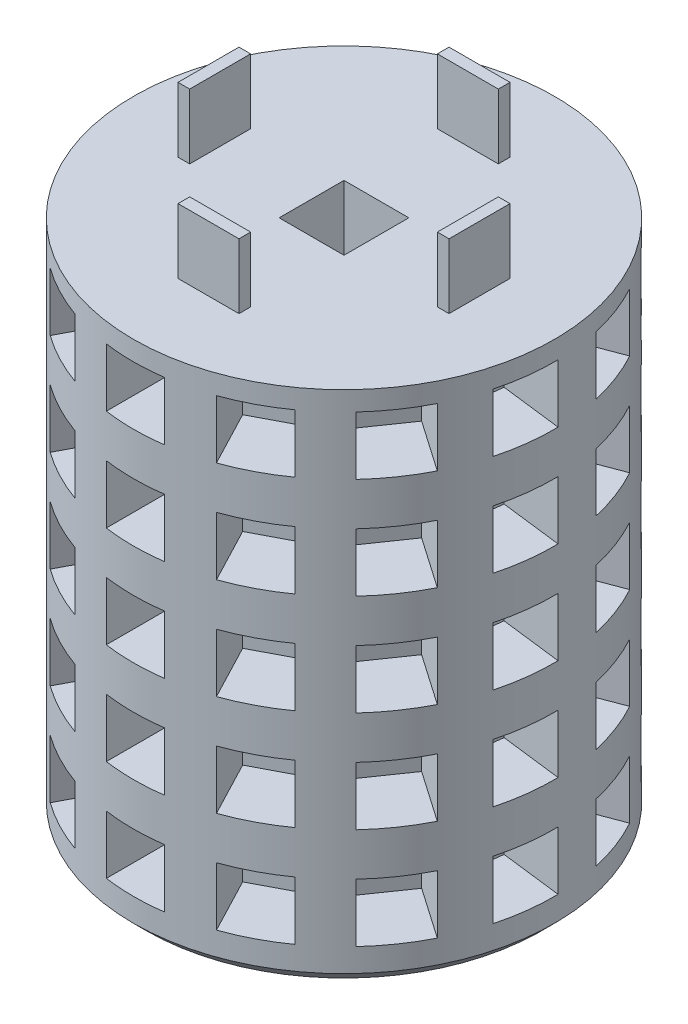
from build123d import *

# Parameters (mm, degrees)
SKETCH1_R                  = 41.2369
BOSS_EXTRUDE1_DEPTH        = 203.2
CUT_EXTRUDE1_DEPTH         = 204.2
CHAMFER1_SIZE              = 2.54
CHAMFER2_SIZE              = 2.54
CUT_EXTRUDE3_DEPTH         = 12.7
LPATTERN1_COUNT            = 10
LPATTERN1_PITCH            = 19.812
CIRPATTERN1_COUNT          = 13
CIRPATTERN1_ANGLE          = 332.4
CIRPATTERN1_COPY_1_DEPTH   = 12.7
CIRPATTERN1_COPY_2_DEPTH   = 12.7
CIRPATTERN1_COPY_3_DEPTH   = 12.7
CIRPATTERN1_COPY_4_DEPTH   = 12.7
CIRPATTERN1_COPY_5_DEPTH   = 12.7
CIRPATTERN1_COPY_6_DEPTH   = 12.7
CIRPATTERN1_COPY_7_DEPTH   = 12.7
CIRPATTERN1_COPY_8_DEPTH   = 12.7
CIRPATTERN1_COPY_9_DEPTH   = 12.7
CIRPATTERN1_COPY_10_DEPTH  = 12.7
CIRPATTERN1_COPY_11_DEPTH  = 12.7
CIRPATTERN1_COPY_12_DEPTH  = 12.7
CIRPATTERN1_COPY_13_DEPTH  = 12.7
CIRPATTERN1_COPY_14_DEPTH  = 12.7
CIRPATTERN1_COPY_15_DEPTH  = 12.7
CIRPATTERN1_COPY_16_DEPTH  = 12.7
CIRPATTERN1_COPY_17_DEPTH  = 12.7
CIRPATTERN1_COPY_18_DEPTH  = 12.7
CIRPATTERN1_COPY_19_DEPTH  = 12.7
CIRPATTERN1_COPY_20_DEPTH  = 12.7
CIRPATTERN1_COPY_21_DEPTH  = 12.7
CIRPATTERN1_COPY_22_DEPTH  = 12.7
CIRPATTERN1_COPY_23_DEPTH  = 12.7
CIRPATTERN1_COPY_24_DEPTH  = 12.7
CIRPATTERN1_COPY_25_DEPTH  = 12.7
CIRPATTERN1_COPY_26_DEPTH  = 12.7
CIRPATTERN1_COPY_27_DEPTH  = 12.7
CIRPATTERN1_COPY_28_DEPTH  = 12.7
CIRPATTERN1_COPY_29_DEPTH  = 12.7
CIRPATTERN1_COPY_30_DEPTH  = 12.7
CIRPATTERN1_COPY_31_DEPTH  = 12.7
CIRPATTERN1_COPY_32_DEPTH  = 12.7
CIRPATTERN1_COPY_33_DEPTH  = 12.7
CIRPATTERN1_COPY_34_DEPTH  = 12.7
CIRPATTERN1_COPY_35_DEPTH  = 12.7
CIRPATTERN1_COPY_36_DEPTH  = 12.7
CIRPATTERN1_COPY_37_DEPTH  = 12.7
CIRPATTERN1_COPY_38_DEPTH  = 12.7
CIRPATTERN1_COPY_39_DEPTH  = 12.7
CIRPATTERN1_COPY_40_DEPTH  = 12.7
CIRPATTERN1_COPY_41_DEPTH  = 12.7
CIRPATTERN1_COPY_42_DEPTH  = 12.7
CIRPATTERN1_COPY_43_DEPTH  = 12.7
CIRPATTERN1_COPY_44_DEPTH  = 12.7
CIRPATTERN1_COPY_45_DEPTH  = 12.7
CIRPATTERN1_COPY_46_DEPTH  = 12.7
CIRPATTERN1_COPY_47_DEPTH  = 12.7
CIRPATTERN1_COPY_48_DEPTH  = 12.7
CIRPATTERN1_COPY_49_DEPTH  = 12.7
CIRPATTERN1_COPY_50_DEPTH  = 12.7
CIRPATTERN1_COPY_51_DEPTH  = 12.7
CIRPATTERN1_COPY_52_DEPTH  = 12.7
CIRPATTERN1_COPY_53_DEPTH  = 12.7
CIRPATTERN1_COPY_54_DEPTH  = 12.7
CIRPATTERN1_COPY_55_DEPTH  = 12.7
CIRPATTERN1_COPY_56_DEPTH  = 12.7
CIRPATTERN1_COPY_57_DEPTH  = 12.7
CIRPATTERN1_COPY_58_DEPTH  = 12.7
CIRPATTERN1_COPY_59_DEPTH  = 12.7
CIRPATTERN1_COPY_60_DEPTH  = 12.7
CIRPATTERN1_COPY_61_DEPTH  = 12.7
CIRPATTERN1_COPY_62_DEPTH  = 12.7
CIRPATTERN1_COPY_63_DEPTH  = 12.7
CIRPATTERN1_COPY_64_DEPTH  = 12.7
CIRPATTERN1_COPY_65_DEPTH  = 12.7
CIRPATTERN1_COPY_66_DEPTH  = 12.7
CIRPATTERN1_COPY_67_DEPTH  = 12.7
CIRPATTERN1_COPY_68_DEPTH  = 12.7
CIRPATTERN1_COPY_69_DEPTH  = 12.7
CIRPATTERN1_COPY_70_DEPTH  = 12.7
CIRPATTERN1_COPY_71_DEPTH  = 12.7
CIRPATTERN1_COPY_72_DEPTH  = 12.7
CIRPATTERN1_COPY_73_DEPTH  = 12.7
CIRPATTERN1_COPY_74_DEPTH  = 12.7
CIRPATTERN1_COPY_75_DEPTH  = 12.7
CIRPATTERN1_COPY_76_DEPTH  = 12.7
CIRPATTERN1_COPY_77_DEPTH  = 12.7
CIRPATTERN1_COPY_78_DEPTH  = 12.7
CIRPATTERN1_COPY_79_DEPTH  = 12.7
CIRPATTERN1_COPY_80_DEPTH  = 12.7
CIRPATTERN1_COPY_81_DEPTH  = 12.7
CIRPATTERN1_COPY_82_DEPTH  = 12.7
CIRPATTERN1_COPY_83_DEPTH  = 12.7
CIRPATTERN1_COPY_84_DEPTH  = 12.7
CIRPATTERN1_COPY_85_DEPTH  = 12.7
CIRPATTERN1_COPY_86_DEPTH  = 12.7
CIRPATTERN1_COPY_87_DEPTH  = 12.7
CIRPATTERN1_COPY_88_DEPTH  = 12.7
CIRPATTERN1_COPY_89_DEPTH  = 12.7
CIRPATTERN1_COPY_90_DEPTH  = 12.7
CIRPATTERN1_COPY_91_DEPTH  = 12.7
CIRPATTERN1_COPY_92_DEPTH  = 12.7
CIRPATTERN1_COPY_93_DEPTH  = 12.7
CIRPATTERN1_COPY_94_DEPTH  = 12.7
CIRPATTERN1_COPY_95_DEPTH  = 12.7
CIRPATTERN1_COPY_96_DEPTH  = 12.7
CIRPATTERN1_COPY_97_DEPTH  = 12.7
CIRPATTERN1_COPY_98_DEPTH  = 12.7
CIRPATTERN1_COPY_99_DEPTH  = 12.7
CIRPATTERN1_COPY_100_DEPTH = 12.7
CIRPATTERN1_COPY_101_DEPTH = 12.7
CIRPATTERN1_COPY_102_DEPTH = 12.7
CIRPATTERN1_COPY_103_DEPTH = 12.7
CIRPATTERN1_COPY_104_DEPTH = 12.7
CIRPATTERN1_COPY_105_DEPTH = 12.7
CIRPATTERN1_COPY_106_DEPTH = 12.7
CIRPATTERN1_COPY_107_DEPTH = 12.7
CIRPATTERN1_COPY_108_DEPTH = 12.7
SKETCH7_R                  = 41.2369
CUT_EXTRUDE4_DEPTH         = 101.6
SKETCH8_W                  = 2.286
SKETCH8_H                  = 11.938
SKETCH8_W_2                = 11.938
SKETCH8_H_2                = 2.286
BOSS_EXTRUDE2_DEPTH        = 12.7


with BuildPart() as part:
    # Sketch1 → Boss-Extrude1 (new body)
    with BuildSketch(Plane(origin=(0, 0, 0), x_dir=(1, 0, 0), z_dir=(0, 1, 0))):
        Circle(SKETCH1_R)
    extrude(amount=BOSS_EXTRUDE1_DEPTH)

    # Sketch2 → Cut-Extrude1 (cut, through all)
    with BuildSketch(Plane(origin=(0, 0, 0), x_dir=(-1, 0, 0), z_dir=(0, -1, 0))):
        Polygon((0, -6.35), (6.35, -6.35), (6.35, 6.35), (0, 6.35), (-6.35, 6.35), (-6.35, -6.35), align=None)
    extrude(amount=-CUT_EXTRUDE1_DEPTH, mode=Mode.SUBTRACT)

    # Chamfer1
    chamfer1_edges = [part.edges().sort_by_distance(p)[0] for p in [
        (-41.2369, 203.2, 0),
    ]]
    chamfer(chamfer1_edges, length=CHAMFER1_SIZE)

    # Chamfer2
    chamfer2_edges = [part.edges().sort_by_distance(p)[0] for p in [
        (-41.2369, 0, 0),
    ]]
    chamfer(chamfer2_edges, length=CHAMFER2_SIZE)

    # Sketch6 → Cut-Extrude3 (cut)
    with BuildSketch(Plane.XY.offset(41.402)):
        Polygon((0, 196.85), (5.715, 196.85), (5.715, 191.135), (5.715, 185.42), (-5.715, 185.42), (-5.715, 191.135), (-5.715, 196.85), align=None)
    cut_extrude3 = extrude(amount=-CUT_EXTRUDE3_DEPTH, mode=Mode.SUBTRACT)

    # LPattern1: Cut-Extrude3 ×10
    with Locations(*[(0, -i * LPATTERN1_PITCH, 0) for i in range(1, LPATTERN1_COUNT)]):
        add(cut_extrude3, mode=Mode.SUBTRACT)

    # CirPattern1: Cut-Extrude3 ×13 about axis
    cirpattern1_axis = Axis((0, 0, 0), (0, -1, 0))
    for i in range(1, CIRPATTERN1_COUNT):
        add(cut_extrude3.rotate(cirpattern1_axis, i * CIRPATTERN1_ANGLE / (CIRPATTERN1_COUNT - 1)), mode=Mode.SUBTRACT)

    # CirPattern1 copy 1 sketch → CirPattern1 copy 1 (cut)
    with BuildSketch(Plane(origin=(-19.245390377, -19.812, 36.657066893), x_dir=(0.885393626, 0, 0.464842046), z_dir=(-0.464842046, 0, 0.885393626))):
        Polygon((0, 196.85), (5.715, 196.85), (5.715, 191.135), (5.715, 185.42), (-5.715, 185.42), (-5.715, 191.135), (-5.715, 196.85), align=None)
    extrude(amount=-CIRPATTERN1_COPY_1_DEPTH, mode=Mode.SUBTRACT)

    # CirPattern1 copy 2 sketch → CirPattern1 copy 2 (cut)
    with BuildSketch(Plane(origin=(-34.07949193, -19.812, 23.509866733), x_dir=(0.567843745, 0, 0.823136369), z_dir=(-0.823136369, 0, 0.567843745))):
        Polygon((0, 196.85), (5.715, 196.85), (5.715, 191.135), (5.715, 185.42), (-5.715, 185.42), (-5.715, 191.135), (-5.715, 196.85), align=None)
    extrude(amount=-CIRPATTERN1_COPY_2_DEPTH, mode=Mode.SUBTRACT)

    # CirPattern1 copy 3 sketch → CirPattern1 copy 3 (cut)
    with BuildSketch(Plane(origin=(-41.102139471, -19.812, 4.973905401), x_dir=(0.120136839, 0, 0.992757342), z_dir=(-0.992757342, 0, 0.120136839))):
        Polygon((0, 196.85), (5.715, 196.85), (5.715, 191.135), (5.715, 185.42), (-5.715, 185.42), (-5.715, 191.135), (-5.715, 196.85), align=None)
    extrude(amount=-CIRPATTERN1_COPY_3_DEPTH, mode=Mode.SUBTRACT)

    # CirPattern1 copy 4 sketch → CirPattern1 copy 4 (cut)
    with BuildSketch(Plane(origin=(-38.703652654, -19.812, -14.702138458), x_dir=(-0.355106962, 0, 0.934825676), z_dir=(-0.934825676, 0, -0.355106962))):
        Polygon((0, 196.85), (5.715, 196.85), (5.715, 191.135), (5.715, 185.42), (-5.715, 185.42), (-5.715, 191.135), (-5.715, 196.85), align=None)
    extrude(amount=-CIRPATTERN1_COPY_4_DEPTH, mode=Mode.SUBTRACT)

    # CirPattern1 copy 5 sketch → CirPattern1 copy 5 (cut)
    with BuildSketch(Plane(origin=(-27.433795236, -19.812, -31.008264752), x_dir=(-0.748955721, 0, 0.662620048), z_dir=(-0.662620048, 0, -0.748955721))):
        Polygon((0, 196.85), (5.715, 196.85), (5.715, 191.135), (5.715, 185.42), (-5.715, 185.42), (-5.715, 191.135), (-5.715, 196.85), align=None)
    extrude(amount=-CIRPATTERN1_COPY_5_DEPTH, mode=Mode.SUBTRACT)

    # CirPattern1 copy 6 sketch → CirPattern1 copy 6 (cut)
    with BuildSketch(Plane(origin=(-9.875762211, -19.812, -40.206901457), x_dir=(-0.97113428, 0, 0.238533458), z_dir=(-0.238533458, 0, -0.97113428))):
        Polygon((0, 196.85), (5.715, 196.85), (5.715, 191.135), (5.715, 185.42), (-5.715, 185.42), (-5.715, 191.135), (-5.715, 196.85), align=None)
    extrude(amount=-CIRPATTERN1_COPY_6_DEPTH, mode=Mode.SUBTRACT)

    # CirPattern1 copy 7 sketch → CirPattern1 copy 7 (cut)
    with BuildSketch(Plane(origin=(9.945921415, -19.812, -40.18960377), x_dir=(-0.970716482, 0, -0.240228042), z_dir=(0.240228042, 0, -0.970716482))):
        Polygon((0, 196.85), (5.715, 196.85), (5.715, 191.135), (5.715, 185.42), (-5.715, 185.42), (-5.715, 191.135), (-5.715, 196.85), align=None)
    extrude(amount=-CIRPATTERN1_COPY_7_DEPTH, mode=Mode.SUBTRACT)

    # CirPattern1 copy 8 sketch → CirPattern1 copy 8 (cut)
    with BuildSketch(Plane(origin=(27.487873056, -19.812, -30.960336543), x_dir=(-0.74779809, 0, -0.663926213), z_dir=(0.663926213, 0, -0.74779809))):
        Polygon((0, 196.85), (5.715, 196.85), (5.715, 191.135), (5.715, 185.42), (-5.715, 185.42), (-5.715, 191.135), (-5.715, 196.85), align=None)
    extrude(amount=-CIRPATTERN1_COPY_8_DEPTH, mode=Mode.SUBTRACT)

    # CirPattern1 copy 9 sketch → CirPattern1 copy 9 (cut)
    with BuildSketch(Plane(origin=(38.729253764, -19.812, -14.634565482), x_dir=(-0.353474844, 0, -0.935444031), z_dir=(0.935444031, 0, -0.353474844))):
        Polygon((0, 196.85), (5.715, 196.85), (5.715, 191.135), (5.715, 185.42), (-5.715, 185.42), (-5.715, 191.135), (-5.715, 196.85), align=None)
    extrude(amount=-CIRPATTERN1_COPY_9_DEPTH, mode=Mode.SUBTRACT)

    # CirPattern1 copy 10 sketch → CirPattern1 copy 10 (cut)
    with BuildSketch(Plane(origin=(41.09339577, -19.812, 5.045634556), x_dir=(0.121869343, 0, -0.992546152), z_dir=(0.992546152, 0, 0.121869343))):
        Polygon((0, 196.85), (5.715, 196.85), (5.715, 191.135), (5.715, 185.42), (-5.715, 185.42), (-5.715, 191.135), (-5.715, 196.85), align=None)
    extrude(amount=-CIRPATTERN1_COPY_10_DEPTH, mode=Mode.SUBTRACT)

    # CirPattern1 copy 11 sketch → CirPattern1 copy 11 (cut)
    with BuildSketch(Plane(origin=(34.038407587, -19.812, 23.569310829), x_dir=(0.569279523, 0, -0.822144041), z_dir=(0.822144041, 0, 0.569279523))):
        Polygon((0, 196.85), (5.715, 196.85), (5.715, 191.135), (5.715, 185.42), (-5.715, 185.42), (-5.715, 191.135), (-5.715, 196.85), align=None)
    extrude(amount=-CIRPATTERN1_COPY_11_DEPTH, mode=Mode.SUBTRACT)

    # CirPattern1 copy 12 sketch → CirPattern1 copy 12 (cut)
    with BuildSketch(Plane(origin=(19.181382446, -19.812, 36.690600587), x_dir=(0.886203579, 0, -0.463296035), z_dir=(0.463296035, 0, 0.886203579))):
        Polygon((0, 196.85), (5.715, 196.85), (5.715, 191.135), (5.715, 185.42), (-5.715, 185.42), (-5.715, 191.135), (-5.715, 196.85), align=None)
    extrude(amount=-CIRPATTERN1_COPY_12_DEPTH, mode=Mode.SUBTRACT)

    # CirPattern1 copy 13 sketch → CirPattern1 copy 13 (cut)
    with BuildSketch(Plane(origin=(-19.245390377, -39.624, 36.657066893), x_dir=(0.885393626, 0, 0.464842046), z_dir=(-0.464842046, 0, 0.885393626))):
        Polygon((0, 196.85), (5.715, 196.85), (5.715, 191.135), (5.715, 185.42), (-5.715, 185.42), (-5.715, 191.135), (-5.715, 196.85), align=None)
    extrude(amount=-CIRPATTERN1_COPY_13_DEPTH, mode=Mode.SUBTRACT)

    # CirPattern1 copy 14 sketch → CirPattern1 copy 14 (cut)
    with BuildSketch(Plane(origin=(-34.07949193, -39.624, 23.509866733), x_dir=(0.567843745, 0, 0.823136369), z_dir=(-0.823136369, 0, 0.567843745))):
        Polygon((0, 196.85), (5.715, 196.85), (5.715, 191.135), (5.715, 185.42), (-5.715, 185.42), (-5.715, 191.135), (-5.715, 196.85), align=None)
    extrude(amount=-CIRPATTERN1_COPY_14_DEPTH, mode=Mode.SUBTRACT)

    # CirPattern1 copy 15 sketch → CirPattern1 copy 15 (cut)
    with BuildSketch(Plane(origin=(-41.102139471, -39.624, 4.973905401), x_dir=(0.120136839, 0, 0.992757342), z_dir=(-0.992757342, 0, 0.120136839))):
        Polygon((0, 196.85), (5.715, 196.85), (5.715, 191.135), (5.715, 185.42), (-5.715, 185.42), (-5.715, 191.135), (-5.715, 196.85), align=None)
    extrude(amount=-CIRPATTERN1_COPY_15_DEPTH, mode=Mode.SUBTRACT)

    # CirPattern1 copy 16 sketch → CirPattern1 copy 16 (cut)
    with BuildSketch(Plane(origin=(-38.703652654, -39.624, -14.702138458), x_dir=(-0.355106962, 0, 0.934825676), z_dir=(-0.934825676, 0, -0.355106962))):
        Polygon((0, 196.85), (5.715, 196.85), (5.715, 191.135), (5.715, 185.42), (-5.715, 185.42), (-5.715, 191.135), (-5.715, 196.85), align=None)
    extrude(amount=-CIRPATTERN1_COPY_16_DEPTH, mode=Mode.SUBTRACT)

    # CirPattern1 copy 17 sketch → CirPattern1 copy 17 (cut)
    with BuildSketch(Plane(origin=(-27.433795236, -39.624, -31.008264752), x_dir=(-0.748955721, 0, 0.662620048), z_dir=(-0.662620048, 0, -0.748955721))):
        Polygon((0, 196.85), (5.715, 196.85), (5.715, 191.135), (5.715, 185.42), (-5.715, 185.42), (-5.715, 191.135), (-5.715, 196.85), align=None)
    extrude(amount=-CIRPATTERN1_COPY_17_DEPTH, mode=Mode.SUBTRACT)

    # CirPattern1 copy 18 sketch → CirPattern1 copy 18 (cut)
    with BuildSketch(Plane(origin=(-9.875762211, -39.624, -40.206901457), x_dir=(-0.97113428, 0, 0.238533458), z_dir=(-0.238533458, 0, -0.97113428))):
        Polygon((0, 196.85), (5.715, 196.85), (5.715, 191.135), (5.715, 185.42), (-5.715, 185.42), (-5.715, 191.135), (-5.715, 196.85), align=None)
    extrude(amount=-CIRPATTERN1_COPY_18_DEPTH, mode=Mode.SUBTRACT)

    # CirPattern1 copy 19 sketch → CirPattern1 copy 19 (cut)
    with BuildSketch(Plane(origin=(9.945921415, -39.624, -40.18960377), x_dir=(-0.970716482, 0, -0.240228042), z_dir=(0.240228042, 0, -0.970716482))):
        Polygon((0, 196.85), (5.715, 196.85), (5.715, 191.135), (5.715, 185.42), (-5.715, 185.42), (-5.715, 191.135), (-5.715, 196.85), align=None)
    extrude(amount=-CIRPATTERN1_COPY_19_DEPTH, mode=Mode.SUBTRACT)

    # CirPattern1 copy 20 sketch → CirPattern1 copy 20 (cut)
    with BuildSketch(Plane(origin=(27.487873056, -39.624, -30.960336543), x_dir=(-0.74779809, 0, -0.663926213), z_dir=(0.663926213, 0, -0.74779809))):
        Polygon((0, 196.85), (5.715, 196.85), (5.715, 191.135), (5.715, 185.42), (-5.715, 185.42), (-5.715, 191.135), (-5.715, 196.85), align=None)
    extrude(amount=-CIRPATTERN1_COPY_20_DEPTH, mode=Mode.SUBTRACT)

    # CirPattern1 copy 21 sketch → CirPattern1 copy 21 (cut)
    with BuildSketch(Plane(origin=(38.729253764, -39.624, -14.634565482), x_dir=(-0.353474844, 0, -0.935444031), z_dir=(0.935444031, 0, -0.353474844))):
        Polygon((0, 196.85), (5.715, 196.85), (5.715, 191.135), (5.715, 185.42), (-5.715, 185.42), (-5.715, 191.135), (-5.715, 196.85), align=None)
    extrude(amount=-CIRPATTERN1_COPY_21_DEPTH, mode=Mode.SUBTRACT)

    # CirPattern1 copy 22 sketch → CirPattern1 copy 22 (cut)
    with BuildSketch(Plane(origin=(41.09339577, -39.624, 5.045634556), x_dir=(0.121869343, 0, -0.992546152), z_dir=(0.992546152, 0, 0.121869343))):
        Polygon((0, 196.85), (5.715, 196.85), (5.715, 191.135), (5.715, 185.42), (-5.715, 185.42), (-5.715, 191.135), (-5.715, 196.85), align=None)
    extrude(amount=-CIRPATTERN1_COPY_22_DEPTH, mode=Mode.SUBTRACT)

    # CirPattern1 copy 23 sketch → CirPattern1 copy 23 (cut)
    with BuildSketch(Plane(origin=(34.038407587, -39.624, 23.569310829), x_dir=(0.569279523, 0, -0.822144041), z_dir=(0.822144041, 0, 0.569279523))):
        Polygon((0, 196.85), (5.715, 196.85), (5.715, 191.135), (5.715, 185.42), (-5.715, 185.42), (-5.715, 191.135), (-5.715, 196.85), align=None)
    extrude(amount=-CIRPATTERN1_COPY_23_DEPTH, mode=Mode.SUBTRACT)

    # CirPattern1 copy 24 sketch → CirPattern1 copy 24 (cut)
    with BuildSketch(Plane(origin=(19.181382446, -39.624, 36.690600587), x_dir=(0.886203579, 0, -0.463296035), z_dir=(0.463296035, 0, 0.886203579))):
        Polygon((0, 196.85), (5.715, 196.85), (5.715, 191.135), (5.715, 185.42), (-5.715, 185.42), (-5.715, 191.135), (-5.715, 196.85), align=None)
    extrude(amount=-CIRPATTERN1_COPY_24_DEPTH, mode=Mode.SUBTRACT)

    # CirPattern1 copy 25 sketch → CirPattern1 copy 25 (cut)
    with BuildSketch(Plane(origin=(-19.245390377, -59.436, 36.657066893), x_dir=(0.885393626, 0, 0.464842046), z_dir=(-0.464842046, 0, 0.885393626))):
        Polygon((0, 196.85), (5.715, 196.85), (5.715, 191.135), (5.715, 185.42), (-5.715, 185.42), (-5.715, 191.135), (-5.715, 196.85), align=None)
    extrude(amount=-CIRPATTERN1_COPY_25_DEPTH, mode=Mode.SUBTRACT)

    # CirPattern1 copy 26 sketch → CirPattern1 copy 26 (cut)
    with BuildSketch(Plane(origin=(-34.07949193, -59.436, 23.509866733), x_dir=(0.567843745, 0, 0.823136369), z_dir=(-0.823136369, 0, 0.567843745))):
        Polygon((0, 196.85), (5.715, 196.85), (5.715, 191.135), (5.715, 185.42), (-5.715, 185.42), (-5.715, 191.135), (-5.715, 196.85), align=None)
    extrude(amount=-CIRPATTERN1_COPY_26_DEPTH, mode=Mode.SUBTRACT)

    # CirPattern1 copy 27 sketch → CirPattern1 copy 27 (cut)
    with BuildSketch(Plane(origin=(-41.102139471, -59.436, 4.973905401), x_dir=(0.120136839, 0, 0.992757342), z_dir=(-0.992757342, 0, 0.120136839))):
        Polygon((0, 196.85), (5.715, 196.85), (5.715, 191.135), (5.715, 185.42), (-5.715, 185.42), (-5.715, 191.135), (-5.715, 196.85), align=None)
    extrude(amount=-CIRPATTERN1_COPY_27_DEPTH, mode=Mode.SUBTRACT)

    # CirPattern1 copy 28 sketch → CirPattern1 copy 28 (cut)
    with BuildSketch(Plane(origin=(-38.703652654, -59.436, -14.702138458), x_dir=(-0.355106962, 0, 0.934825676), z_dir=(-0.934825676, 0, -0.355106962))):
        Polygon((0, 196.85), (5.715, 196.85), (5.715, 191.135), (5.715, 185.42), (-5.715, 185.42), (-5.715, 191.135), (-5.715, 196.85), align=None)
    extrude(amount=-CIRPATTERN1_COPY_28_DEPTH, mode=Mode.SUBTRACT)

    # CirPattern1 copy 29 sketch → CirPattern1 copy 29 (cut)
    with BuildSketch(Plane(origin=(-27.433795236, -59.436, -31.008264752), x_dir=(-0.748955721, 0, 0.662620048), z_dir=(-0.662620048, 0, -0.748955721))):
        Polygon((0, 196.85), (5.715, 196.85), (5.715, 191.135), (5.715, 185.42), (-5.715, 185.42), (-5.715, 191.135), (-5.715, 196.85), align=None)
    extrude(amount=-CIRPATTERN1_COPY_29_DEPTH, mode=Mode.SUBTRACT)

    # CirPattern1 copy 30 sketch → CirPattern1 copy 30 (cut)
    with BuildSketch(Plane(origin=(-9.875762211, -59.436, -40.206901457), x_dir=(-0.97113428, 0, 0.238533458), z_dir=(-0.238533458, 0, -0.97113428))):
        Polygon((0, 196.85), (5.715, 196.85), (5.715, 191.135), (5.715, 185.42), (-5.715, 185.42), (-5.715, 191.135), (-5.715, 196.85), align=None)
    extrude(amount=-CIRPATTERN1_COPY_30_DEPTH, mode=Mode.SUBTRACT)

    # CirPattern1 copy 31 sketch → CirPattern1 copy 31 (cut)
    with BuildSketch(Plane(origin=(9.945921415, -59.436, -40.18960377), x_dir=(-0.970716482, 0, -0.240228042), z_dir=(0.240228042, 0, -0.970716482))):
        Polygon((0, 196.85), (5.715, 196.85), (5.715, 191.135), (5.715, 185.42), (-5.715, 185.42), (-5.715, 191.135), (-5.715, 196.85), align=None)
    extrude(amount=-CIRPATTERN1_COPY_31_DEPTH, mode=Mode.SUBTRACT)

    # CirPattern1 copy 32 sketch → CirPattern1 copy 32 (cut)
    with BuildSketch(Plane(origin=(27.487873056, -59.436, -30.960336543), x_dir=(-0.74779809, 0, -0.663926213), z_dir=(0.663926213, 0, -0.74779809))):
        Polygon((0, 196.85), (5.715, 196.85), (5.715, 191.135), (5.715, 185.42), (-5.715, 185.42), (-5.715, 191.135), (-5.715, 196.85), align=None)
    extrude(amount=-CIRPATTERN1_COPY_32_DEPTH, mode=Mode.SUBTRACT)

    # CirPattern1 copy 33 sketch → CirPattern1 copy 33 (cut)
    with BuildSketch(Plane(origin=(38.729253764, -59.436, -14.634565482), x_dir=(-0.353474844, 0, -0.935444031), z_dir=(0.935444031, 0, -0.353474844))):
        Polygon((0, 196.85), (5.715, 196.85), (5.715, 191.135), (5.715, 185.42), (-5.715, 185.42), (-5.715, 191.135), (-5.715, 196.85), align=None)
    extrude(amount=-CIRPATTERN1_COPY_33_DEPTH, mode=Mode.SUBTRACT)

    # CirPattern1 copy 34 sketch → CirPattern1 copy 34 (cut)
    with BuildSketch(Plane(origin=(41.09339577, -59.436, 5.045634556), x_dir=(0.121869343, 0, -0.992546152), z_dir=(0.992546152, 0, 0.121869343))):
        Polygon((0, 196.85), (5.715, 196.85), (5.715, 191.135), (5.715, 185.42), (-5.715, 185.42), (-5.715, 191.135), (-5.715, 196.85), align=None)
    extrude(amount=-CIRPATTERN1_COPY_34_DEPTH, mode=Mode.SUBTRACT)

    # CirPattern1 copy 35 sketch → CirPattern1 copy 35 (cut)
    with BuildSketch(Plane(origin=(34.038407587, -59.436, 23.569310829), x_dir=(0.569279523, 0, -0.822144041), z_dir=(0.822144041, 0, 0.569279523))):
        Polygon((0, 196.85), (5.715, 196.85), (5.715, 191.135), (5.715, 185.42), (-5.715, 185.42), (-5.715, 191.135), (-5.715, 196.85), align=None)
    extrude(amount=-CIRPATTERN1_COPY_35_DEPTH, mode=Mode.SUBTRACT)

    # CirPattern1 copy 36 sketch → CirPattern1 copy 36 (cut)
    with BuildSketch(Plane(origin=(19.181382446, -59.436, 36.690600587), x_dir=(0.886203579, 0, -0.463296035), z_dir=(0.463296035, 0, 0.886203579))):
        Polygon((0, 196.85), (5.715, 196.85), (5.715, 191.135), (5.715, 185.42), (-5.715, 185.42), (-5.715, 191.135), (-5.715, 196.85), align=None)
    extrude(amount=-CIRPATTERN1_COPY_36_DEPTH, mode=Mode.SUBTRACT)

    # CirPattern1 copy 37 sketch → CirPattern1 copy 37 (cut)
    with BuildSketch(Plane(origin=(-19.245390377, -79.248, 36.657066893), x_dir=(0.885393626, 0, 0.464842046), z_dir=(-0.464842046, 0, 0.885393626))):
        Polygon((0, 196.85), (5.715, 196.85), (5.715, 191.135), (5.715, 185.42), (-5.715, 185.42), (-5.715, 191.135), (-5.715, 196.85), align=None)
    extrude(amount=-CIRPATTERN1_COPY_37_DEPTH, mode=Mode.SUBTRACT)

    # CirPattern1 copy 38 sketch → CirPattern1 copy 38 (cut)
    with BuildSketch(Plane(origin=(-34.07949193, -79.248, 23.509866733), x_dir=(0.567843745, 0, 0.823136369), z_dir=(-0.823136369, 0, 0.567843745))):
        Polygon((0, 196.85), (5.715, 196.85), (5.715, 191.135), (5.715, 185.42), (-5.715, 185.42), (-5.715, 191.135), (-5.715, 196.85), align=None)
    extrude(amount=-CIRPATTERN1_COPY_38_DEPTH, mode=Mode.SUBTRACT)

    # CirPattern1 copy 39 sketch → CirPattern1 copy 39 (cut)
    with BuildSketch(Plane(origin=(-41.102139471, -79.248, 4.973905401), x_dir=(0.120136839, 0, 0.992757342), z_dir=(-0.992757342, 0, 0.120136839))):
        Polygon((0, 196.85), (5.715, 196.85), (5.715, 191.135), (5.715, 185.42), (-5.715, 185.42), (-5.715, 191.135), (-5.715, 196.85), align=None)
    extrude(amount=-CIRPATTERN1_COPY_39_DEPTH, mode=Mode.SUBTRACT)

    # CirPattern1 copy 40 sketch → CirPattern1 copy 40 (cut)
    with BuildSketch(Plane(origin=(-38.703652654, -79.248, -14.702138458), x_dir=(-0.355106962, 0, 0.934825676), z_dir=(-0.934825676, 0, -0.355106962))):
        Polygon((0, 196.85), (5.715, 196.85), (5.715, 191.135), (5.715, 185.42), (-5.715, 185.42), (-5.715, 191.135), (-5.715, 196.85), align=None)
    extrude(amount=-CIRPATTERN1_COPY_40_DEPTH, mode=Mode.SUBTRACT)

    # CirPattern1 copy 41 sketch → CirPattern1 copy 41 (cut)
    with BuildSketch(Plane(origin=(-27.433795236, -79.248, -31.008264752), x_dir=(-0.748955721, 0, 0.662620048), z_dir=(-0.662620048, 0, -0.748955721))):
        Polygon((0, 196.85), (5.715, 196.85), (5.715, 191.135), (5.715, 185.42), (-5.715, 185.42), (-5.715, 191.135), (-5.715, 196.85), align=None)
    extrude(amount=-CIRPATTERN1_COPY_41_DEPTH, mode=Mode.SUBTRACT)

    # CirPattern1 copy 42 sketch → CirPattern1 copy 42 (cut)
    with BuildSketch(Plane(origin=(-9.875762211, -79.248, -40.206901457), x_dir=(-0.97113428, 0, 0.238533458), z_dir=(-0.238533458, 0, -0.97113428))):
        Polygon((0, 196.85), (5.715, 196.85), (5.715, 191.135), (5.715, 185.42), (-5.715, 185.42), (-5.715, 191.135), (-5.715, 196.85), align=None)
    extrude(amount=-CIRPATTERN1_COPY_42_DEPTH, mode=Mode.SUBTRACT)

    # CirPattern1 copy 43 sketch → CirPattern1 copy 43 (cut)
    with BuildSketch(Plane(origin=(9.945921415, -79.248, -40.18960377), x_dir=(-0.970716482, 0, -0.240228042), z_dir=(0.240228042, 0, -0.970716482))):
        Polygon((0, 196.85), (5.715, 196.85), (5.715, 191.135), (5.715, 185.42), (-5.715, 185.42), (-5.715, 191.135), (-5.715, 196.85), align=None)
    extrude(amount=-CIRPATTERN1_COPY_43_DEPTH, mode=Mode.SUBTRACT)

    # CirPattern1 copy 44 sketch → CirPattern1 copy 44 (cut)
    with BuildSketch(Plane(origin=(27.487873056, -79.248, -30.960336543), x_dir=(-0.74779809, 0, -0.663926213), z_dir=(0.663926213, 0, -0.74779809))):
        Polygon((0, 196.85), (5.715, 196.85), (5.715, 191.135), (5.715, 185.42), (-5.715, 185.42), (-5.715, 191.135), (-5.715, 196.85), align=None)
    extrude(amount=-CIRPATTERN1_COPY_44_DEPTH, mode=Mode.SUBTRACT)

    # CirPattern1 copy 45 sketch → CirPattern1 copy 45 (cut)
    with BuildSketch(Plane(origin=(38.729253764, -79.248, -14.634565482), x_dir=(-0.353474844, 0, -0.935444031), z_dir=(0.935444031, 0, -0.353474844))):
        Polygon((0, 196.85), (5.715, 196.85), (5.715, 191.135), (5.715, 185.42), (-5.715, 185.42), (-5.715, 191.135), (-5.715, 196.85), align=None)
    extrude(amount=-CIRPATTERN1_COPY_45_DEPTH, mode=Mode.SUBTRACT)

    # CirPattern1 copy 46 sketch → CirPattern1 copy 46 (cut)
    with BuildSketch(Plane(origin=(41.09339577, -79.248, 5.045634556), x_dir=(0.121869343, 0, -0.992546152), z_dir=(0.992546152, 0, 0.121869343))):
        Polygon((0, 196.85), (5.715, 196.85), (5.715, 191.135), (5.715, 185.42), (-5.715, 185.42), (-5.715, 191.135), (-5.715, 196.85), align=None)
    extrude(amount=-CIRPATTERN1_COPY_46_DEPTH, mode=Mode.SUBTRACT)

    # CirPattern1 copy 47 sketch → CirPattern1 copy 47 (cut)
    with BuildSketch(Plane(origin=(34.038407587, -79.248, 23.569310829), x_dir=(0.569279523, 0, -0.822144041), z_dir=(0.822144041, 0, 0.569279523))):
        Polygon((0, 196.85), (5.715, 196.85), (5.715, 191.135), (5.715, 185.42), (-5.715, 185.42), (-5.715, 191.135), (-5.715, 196.85), align=None)
    extrude(amount=-CIRPATTERN1_COPY_47_DEPTH, mode=Mode.SUBTRACT)

    # CirPattern1 copy 48 sketch → CirPattern1 copy 48 (cut)
    with BuildSketch(Plane(origin=(19.181382446, -79.248, 36.690600587), x_dir=(0.886203579, 0, -0.463296035), z_dir=(0.463296035, 0, 0.886203579))):
        Polygon((0, 196.85), (5.715, 196.85), (5.715, 191.135), (5.715, 185.42), (-5.715, 185.42), (-5.715, 191.135), (-5.715, 196.85), align=None)
    extrude(amount=-CIRPATTERN1_COPY_48_DEPTH, mode=Mode.SUBTRACT)

    # CirPattern1 copy 49 sketch → CirPattern1 copy 49 (cut)
    with BuildSketch(Plane(origin=(-19.245390377, -99.06, 36.657066893), x_dir=(0.885393626, 0, 0.464842046), z_dir=(-0.464842046, 0, 0.885393626))):
        Polygon((0, 196.85), (5.715, 196.85), (5.715, 191.135), (5.715, 185.42), (-5.715, 185.42), (-5.715, 191.135), (-5.715, 196.85), align=None)
    extrude(amount=-CIRPATTERN1_COPY_49_DEPTH, mode=Mode.SUBTRACT)

    # CirPattern1 copy 50 sketch → CirPattern1 copy 50 (cut)
    with BuildSketch(Plane(origin=(-34.07949193, -99.06, 23.509866733), x_dir=(0.567843745, 0, 0.823136369), z_dir=(-0.823136369, 0, 0.567843745))):
        Polygon((0, 196.85), (5.715, 196.85), (5.715, 191.135), (5.715, 185.42), (-5.715, 185.42), (-5.715, 191.135), (-5.715, 196.85), align=None)
    extrude(amount=-CIRPATTERN1_COPY_50_DEPTH, mode=Mode.SUBTRACT)

    # CirPattern1 copy 51 sketch → CirPattern1 copy 51 (cut)
    with BuildSketch(Plane(origin=(-41.102139471, -99.06, 4.973905401), x_dir=(0.120136839, 0, 0.992757342), z_dir=(-0.992757342, 0, 0.120136839))):
        Polygon((0, 196.85), (5.715, 196.85), (5.715, 191.135), (5.715, 185.42), (-5.715, 185.42), (-5.715, 191.135), (-5.715, 196.85), align=None)
    extrude(amount=-CIRPATTERN1_COPY_51_DEPTH, mode=Mode.SUBTRACT)

    # CirPattern1 copy 52 sketch → CirPattern1 copy 52 (cut)
    with BuildSketch(Plane(origin=(-38.703652654, -99.06, -14.702138458), x_dir=(-0.355106962, 0, 0.934825676), z_dir=(-0.934825676, 0, -0.355106962))):
        Polygon((0, 196.85), (5.715, 196.85), (5.715, 191.135), (5.715, 185.42), (-5.715, 185.42), (-5.715, 191.135), (-5.715, 196.85), align=None)
    extrude(amount=-CIRPATTERN1_COPY_52_DEPTH, mode=Mode.SUBTRACT)

    # CirPattern1 copy 53 sketch → CirPattern1 copy 53 (cut)
    with BuildSketch(Plane(origin=(-27.433795236, -99.06, -31.008264752), x_dir=(-0.748955721, 0, 0.662620048), z_dir=(-0.662620048, 0, -0.748955721))):
        Polygon((0, 196.85), (5.715, 196.85), (5.715, 191.135), (5.715, 185.42), (-5.715, 185.42), (-5.715, 191.135), (-5.715, 196.85), align=None)
    extrude(amount=-CIRPATTERN1_COPY_53_DEPTH, mode=Mode.SUBTRACT)

    # CirPattern1 copy 54 sketch → CirPattern1 copy 54 (cut)
    with BuildSketch(Plane(origin=(-9.875762211, -99.06, -40.206901457), x_dir=(-0.97113428, 0, 0.238533458), z_dir=(-0.238533458, 0, -0.97113428))):
        Polygon((0, 196.85), (5.715, 196.85), (5.715, 191.135), (5.715, 185.42), (-5.715, 185.42), (-5.715, 191.135), (-5.715, 196.85), align=None)
    extrude(amount=-CIRPATTERN1_COPY_54_DEPTH, mode=Mode.SUBTRACT)

    # CirPattern1 copy 55 sketch → CirPattern1 copy 55 (cut)
    with BuildSketch(Plane(origin=(9.945921415, -99.06, -40.18960377), x_dir=(-0.970716482, 0, -0.240228042), z_dir=(0.240228042, 0, -0.970716482))):
        Polygon((0, 196.85), (5.715, 196.85), (5.715, 191.135), (5.715, 185.42), (-5.715, 185.42), (-5.715, 191.135), (-5.715, 196.85), align=None)
    extrude(amount=-CIRPATTERN1_COPY_55_DEPTH, mode=Mode.SUBTRACT)

    # CirPattern1 copy 56 sketch → CirPattern1 copy 56 (cut)
    with BuildSketch(Plane(origin=(27.487873056, -99.06, -30.960336543), x_dir=(-0.74779809, 0, -0.663926213), z_dir=(0.663926213, 0, -0.74779809))):
        Polygon((0, 196.85), (5.715, 196.85), (5.715, 191.135), (5.715, 185.42), (-5.715, 185.42), (-5.715, 191.135), (-5.715, 196.85), align=None)
    extrude(amount=-CIRPATTERN1_COPY_56_DEPTH, mode=Mode.SUBTRACT)

    # CirPattern1 copy 57 sketch → CirPattern1 copy 57 (cut)
    with BuildSketch(Plane(origin=(38.729253764, -99.06, -14.634565482), x_dir=(-0.353474844, 0, -0.935444031), z_dir=(0.935444031, 0, -0.353474844))):
        Polygon((0, 196.85), (5.715, 196.85), (5.715, 191.135), (5.715, 185.42), (-5.715, 185.42), (-5.715, 191.135), (-5.715, 196.85), align=None)
    extrude(amount=-CIRPATTERN1_COPY_57_DEPTH, mode=Mode.SUBTRACT)

    # CirPattern1 copy 58 sketch → CirPattern1 copy 58 (cut)
    with BuildSketch(Plane(origin=(41.09339577, -99.06, 5.045634556), x_dir=(0.121869343, 0, -0.992546152), z_dir=(0.992546152, 0, 0.121869343))):
        Polygon((0, 196.85), (5.715, 196.85), (5.715, 191.135), (5.715, 185.42), (-5.715, 185.42), (-5.715, 191.135), (-5.715, 196.85), align=None)
    extrude(amount=-CIRPATTERN1_COPY_58_DEPTH, mode=Mode.SUBTRACT)

    # CirPattern1 copy 59 sketch → CirPattern1 copy 59 (cut)
    with BuildSketch(Plane(origin=(34.038407587, -99.06, 23.569310829), x_dir=(0.569279523, 0, -0.822144041), z_dir=(0.822144041, 0, 0.569279523))):
        Polygon((0, 196.85), (5.715, 196.85), (5.715, 191.135), (5.715, 185.42), (-5.715, 185.42), (-5.715, 191.135), (-5.715, 196.85), align=None)
    extrude(amount=-CIRPATTERN1_COPY_59_DEPTH, mode=Mode.SUBTRACT)

    # CirPattern1 copy 60 sketch → CirPattern1 copy 60 (cut)
    with BuildSketch(Plane(origin=(19.181382446, -99.06, 36.690600587), x_dir=(0.886203579, 0, -0.463296035), z_dir=(0.463296035, 0, 0.886203579))):
        Polygon((0, 196.85), (5.715, 196.85), (5.715, 191.135), (5.715, 185.42), (-5.715, 185.42), (-5.715, 191.135), (-5.715, 196.85), align=None)
    extrude(amount=-CIRPATTERN1_COPY_60_DEPTH, mode=Mode.SUBTRACT)

    # CirPattern1 copy 61 sketch → CirPattern1 copy 61 (cut)
    with BuildSketch(Plane(origin=(-19.245390377, -118.872, 36.657066893), x_dir=(0.885393626, 0, 0.464842046), z_dir=(-0.464842046, 0, 0.885393626))):
        Polygon((0, 196.85), (5.715, 196.85), (5.715, 191.135), (5.715, 185.42), (-5.715, 185.42), (-5.715, 191.135), (-5.715, 196.85), align=None)
    extrude(amount=-CIRPATTERN1_COPY_61_DEPTH, mode=Mode.SUBTRACT)

    # CirPattern1 copy 62 sketch → CirPattern1 copy 62 (cut)
    with BuildSketch(Plane(origin=(-34.07949193, -118.872, 23.509866733), x_dir=(0.567843745, 0, 0.823136369), z_dir=(-0.823136369, 0, 0.567843745))):
        Polygon((0, 196.85), (5.715, 196.85), (5.715, 191.135), (5.715, 185.42), (-5.715, 185.42), (-5.715, 191.135), (-5.715, 196.85), align=None)
    extrude(amount=-CIRPATTERN1_COPY_62_DEPTH, mode=Mode.SUBTRACT)

    # CirPattern1 copy 63 sketch → CirPattern1 copy 63 (cut)
    with BuildSketch(Plane(origin=(-41.102139471, -118.872, 4.973905401), x_dir=(0.120136839, 0, 0.992757342), z_dir=(-0.992757342, 0, 0.120136839))):
        Polygon((0, 196.85), (5.715, 196.85), (5.715, 191.135), (5.715, 185.42), (-5.715, 185.42), (-5.715, 191.135), (-5.715, 196.85), align=None)
    extrude(amount=-CIRPATTERN1_COPY_63_DEPTH, mode=Mode.SUBTRACT)

    # CirPattern1 copy 64 sketch → CirPattern1 copy 64 (cut)
    with BuildSketch(Plane(origin=(-38.703652654, -118.872, -14.702138458), x_dir=(-0.355106962, 0, 0.934825676), z_dir=(-0.934825676, 0, -0.355106962))):
        Polygon((0, 196.85), (5.715, 196.85), (5.715, 191.135), (5.715, 185.42), (-5.715, 185.42), (-5.715, 191.135), (-5.715, 196.85), align=None)
    extrude(amount=-CIRPATTERN1_COPY_64_DEPTH, mode=Mode.SUBTRACT)

    # CirPattern1 copy 65 sketch → CirPattern1 copy 65 (cut)
    with BuildSketch(Plane(origin=(-27.433795236, -118.872, -31.008264752), x_dir=(-0.748955721, 0, 0.662620048), z_dir=(-0.662620048, 0, -0.748955721))):
        Polygon((0, 196.85), (5.715, 196.85), (5.715, 191.135), (5.715, 185.42), (-5.715, 185.42), (-5.715, 191.135), (-5.715, 196.85), align=None)
    extrude(amount=-CIRPATTERN1_COPY_65_DEPTH, mode=Mode.SUBTRACT)

    # CirPattern1 copy 66 sketch → CirPattern1 copy 66 (cut)
    with BuildSketch(Plane(origin=(-9.875762211, -118.872, -40.206901457), x_dir=(-0.97113428, 0, 0.238533458), z_dir=(-0.238533458, 0, -0.97113428))):
        Polygon((0, 196.85), (5.715, 196.85), (5.715, 191.135), (5.715, 185.42), (-5.715, 185.42), (-5.715, 191.135), (-5.715, 196.85), align=None)
    extrude(amount=-CIRPATTERN1_COPY_66_DEPTH, mode=Mode.SUBTRACT)

    # CirPattern1 copy 67 sketch → CirPattern1 copy 67 (cut)
    with BuildSketch(Plane(origin=(9.945921415, -118.872, -40.18960377), x_dir=(-0.970716482, 0, -0.240228042), z_dir=(0.240228042, 0, -0.970716482))):
        Polygon((0, 196.85), (5.715, 196.85), (5.715, 191.135), (5.715, 185.42), (-5.715, 185.42), (-5.715, 191.135), (-5.715, 196.85), align=None)
    extrude(amount=-CIRPATTERN1_COPY_67_DEPTH, mode=Mode.SUBTRACT)

    # CirPattern1 copy 68 sketch → CirPattern1 copy 68 (cut)
    with BuildSketch(Plane(origin=(27.487873056, -118.872, -30.960336543), x_dir=(-0.74779809, 0, -0.663926213), z_dir=(0.663926213, 0, -0.74779809))):
        Polygon((0, 196.85), (5.715, 196.85), (5.715, 191.135), (5.715, 185.42), (-5.715, 185.42), (-5.715, 191.135), (-5.715, 196.85), align=None)
    extrude(amount=-CIRPATTERN1_COPY_68_DEPTH, mode=Mode.SUBTRACT)

    # CirPattern1 copy 69 sketch → CirPattern1 copy 69 (cut)
    with BuildSketch(Plane(origin=(38.729253764, -118.872, -14.634565482), x_dir=(-0.353474844, 0, -0.935444031), z_dir=(0.935444031, 0, -0.353474844))):
        Polygon((0, 196.85), (5.715, 196.85), (5.715, 191.135), (5.715, 185.42), (-5.715, 185.42), (-5.715, 191.135), (-5.715, 196.85), align=None)
    extrude(amount=-CIRPATTERN1_COPY_69_DEPTH, mode=Mode.SUBTRACT)

    # CirPattern1 copy 70 sketch → CirPattern1 copy 70 (cut)
    with BuildSketch(Plane(origin=(41.09339577, -118.872, 5.045634556), x_dir=(0.121869343, 0, -0.992546152), z_dir=(0.992546152, 0, 0.121869343))):
        Polygon((0, 196.85), (5.715, 196.85), (5.715, 191.135), (5.715, 185.42), (-5.715, 185.42), (-5.715, 191.135), (-5.715, 196.85), align=None)
    extrude(amount=-CIRPATTERN1_COPY_70_DEPTH, mode=Mode.SUBTRACT)

    # CirPattern1 copy 71 sketch → CirPattern1 copy 71 (cut)
    with BuildSketch(Plane(origin=(34.038407587, -118.872, 23.569310829), x_dir=(0.569279523, 0, -0.822144041), z_dir=(0.822144041, 0, 0.569279523))):
        Polygon((0, 196.85), (5.715, 196.85), (5.715, 191.135), (5.715, 185.42), (-5.715, 185.42), (-5.715, 191.135), (-5.715, 196.85), align=None)
    extrude(amount=-CIRPATTERN1_COPY_71_DEPTH, mode=Mode.SUBTRACT)

    # CirPattern1 copy 72 sketch → CirPattern1 copy 72 (cut)
    with BuildSketch(Plane(origin=(19.181382446, -118.872, 36.690600587), x_dir=(0.886203579, 0, -0.463296035), z_dir=(0.463296035, 0, 0.886203579))):
        Polygon((0, 196.85), (5.715, 196.85), (5.715, 191.135), (5.715, 185.42), (-5.715, 185.42), (-5.715, 191.135), (-5.715, 196.85), align=None)
    extrude(amount=-CIRPATTERN1_COPY_72_DEPTH, mode=Mode.SUBTRACT)

    # CirPattern1 copy 73 sketch → CirPattern1 copy 73 (cut)
    with BuildSketch(Plane(origin=(-19.245390377, -138.684, 36.657066893), x_dir=(0.885393626, 0, 0.464842046), z_dir=(-0.464842046, 0, 0.885393626))):
        Polygon((0, 196.85), (5.715, 196.85), (5.715, 191.135), (5.715, 185.42), (-5.715, 185.42), (-5.715, 191.135), (-5.715, 196.85), align=None)
    extrude(amount=-CIRPATTERN1_COPY_73_DEPTH, mode=Mode.SUBTRACT)

    # CirPattern1 copy 74 sketch → CirPattern1 copy 74 (cut)
    with BuildSketch(Plane(origin=(-34.07949193, -138.684, 23.509866733), x_dir=(0.567843745, 0, 0.823136369), z_dir=(-0.823136369, 0, 0.567843745))):
        Polygon((0, 196.85), (5.715, 196.85), (5.715, 191.135), (5.715, 185.42), (-5.715, 185.42), (-5.715, 191.135), (-5.715, 196.85), align=None)
    extrude(amount=-CIRPATTERN1_COPY_74_DEPTH, mode=Mode.SUBTRACT)

    # CirPattern1 copy 75 sketch → CirPattern1 copy 75 (cut)
    with BuildSketch(Plane(origin=(-41.102139471, -138.684, 4.973905401), x_dir=(0.120136839, 0, 0.992757342), z_dir=(-0.992757342, 0, 0.120136839))):
        Polygon((0, 196.85), (5.715, 196.85), (5.715, 191.135), (5.715, 185.42), (-5.715, 185.42), (-5.715, 191.135), (-5.715, 196.85), align=None)
    extrude(amount=-CIRPATTERN1_COPY_75_DEPTH, mode=Mode.SUBTRACT)

    # CirPattern1 copy 76 sketch → CirPattern1 copy 76 (cut)
    with BuildSketch(Plane(origin=(-38.703652654, -138.684, -14.702138458), x_dir=(-0.355106962, 0, 0.934825676), z_dir=(-0.934825676, 0, -0.355106962))):
        Polygon((0, 196.85), (5.715, 196.85), (5.715, 191.135), (5.715, 185.42), (-5.715, 185.42), (-5.715, 191.135), (-5.715, 196.85), align=None)
    extrude(amount=-CIRPATTERN1_COPY_76_DEPTH, mode=Mode.SUBTRACT)

    # CirPattern1 copy 77 sketch → CirPattern1 copy 77 (cut)
    with BuildSketch(Plane(origin=(-27.433795236, -138.684, -31.008264752), x_dir=(-0.748955721, 0, 0.662620048), z_dir=(-0.662620048, 0, -0.748955721))):
        Polygon((0, 196.85), (5.715, 196.85), (5.715, 191.135), (5.715, 185.42), (-5.715, 185.42), (-5.715, 191.135), (-5.715, 196.85), align=None)
    extrude(amount=-CIRPATTERN1_COPY_77_DEPTH, mode=Mode.SUBTRACT)

    # CirPattern1 copy 78 sketch → CirPattern1 copy 78 (cut)
    with BuildSketch(Plane(origin=(-9.875762211, -138.684, -40.206901457), x_dir=(-0.97113428, 0, 0.238533458), z_dir=(-0.238533458, 0, -0.97113428))):
        Polygon((0, 196.85), (5.715, 196.85), (5.715, 191.135), (5.715, 185.42), (-5.715, 185.42), (-5.715, 191.135), (-5.715, 196.85), align=None)
    extrude(amount=-CIRPATTERN1_COPY_78_DEPTH, mode=Mode.SUBTRACT)

    # CirPattern1 copy 79 sketch → CirPattern1 copy 79 (cut)
    with BuildSketch(Plane(origin=(9.945921415, -138.684, -40.18960377), x_dir=(-0.970716482, 0, -0.240228042), z_dir=(0.240228042, 0, -0.970716482))):
        Polygon((0, 196.85), (5.715, 196.85), (5.715, 191.135), (5.715, 185.42), (-5.715, 185.42), (-5.715, 191.135), (-5.715, 196.85), align=None)
    extrude(amount=-CIRPATTERN1_COPY_79_DEPTH, mode=Mode.SUBTRACT)

    # CirPattern1 copy 80 sketch → CirPattern1 copy 80 (cut)
    with BuildSketch(Plane(origin=(27.487873056, -138.684, -30.960336543), x_dir=(-0.74779809, 0, -0.663926213), z_dir=(0.663926213, 0, -0.74779809))):
        Polygon((0, 196.85), (5.715, 196.85), (5.715, 191.135), (5.715, 185.42), (-5.715, 185.42), (-5.715, 191.135), (-5.715, 196.85), align=None)
    extrude(amount=-CIRPATTERN1_COPY_80_DEPTH, mode=Mode.SUBTRACT)

    # CirPattern1 copy 81 sketch → CirPattern1 copy 81 (cut)
    with BuildSketch(Plane(origin=(38.729253764, -138.684, -14.634565482), x_dir=(-0.353474844, 0, -0.935444031), z_dir=(0.935444031, 0, -0.353474844))):
        Polygon((0, 196.85), (5.715, 196.85), (5.715, 191.135), (5.715, 185.42), (-5.715, 185.42), (-5.715, 191.135), (-5.715, 196.85), align=None)
    extrude(amount=-CIRPATTERN1_COPY_81_DEPTH, mode=Mode.SUBTRACT)

    # CirPattern1 copy 82 sketch → CirPattern1 copy 82 (cut)
    with BuildSketch(Plane(origin=(41.09339577, -138.684, 5.045634556), x_dir=(0.121869343, 0, -0.992546152), z_dir=(0.992546152, 0, 0.121869343))):
        Polygon((0, 196.85), (5.715, 196.85), (5.715, 191.135), (5.715, 185.42), (-5.715, 185.42), (-5.715, 191.135), (-5.715, 196.85), align=None)
    extrude(amount=-CIRPATTERN1_COPY_82_DEPTH, mode=Mode.SUBTRACT)

    # CirPattern1 copy 83 sketch → CirPattern1 copy 83 (cut)
    with BuildSketch(Plane(origin=(34.038407587, -138.684, 23.569310829), x_dir=(0.569279523, 0, -0.822144041), z_dir=(0.822144041, 0, 0.569279523))):
        Polygon((0, 196.85), (5.715, 196.85), (5.715, 191.135), (5.715, 185.42), (-5.715, 185.42), (-5.715, 191.135), (-5.715, 196.85), align=None)
    extrude(amount=-CIRPATTERN1_COPY_83_DEPTH, mode=Mode.SUBTRACT)

    # CirPattern1 copy 84 sketch → CirPattern1 copy 84 (cut)
    with BuildSketch(Plane(origin=(19.181382446, -138.684, 36.690600587), x_dir=(0.886203579, 0, -0.463296035), z_dir=(0.463296035, 0, 0.886203579))):
        Polygon((0, 196.85), (5.715, 196.85), (5.715, 191.135), (5.715, 185.42), (-5.715, 185.42), (-5.715, 191.135), (-5.715, 196.85), align=None)
    extrude(amount=-CIRPATTERN1_COPY_84_DEPTH, mode=Mode.SUBTRACT)

    # CirPattern1 copy 85 sketch → CirPattern1 copy 85 (cut)
    with BuildSketch(Plane(origin=(-19.245390377, -158.496, 36.657066893), x_dir=(0.885393626, 0, 0.464842046), z_dir=(-0.464842046, 0, 0.885393626))):
        Polygon((0, 196.85), (5.715, 196.85), (5.715, 191.135), (5.715, 185.42), (-5.715, 185.42), (-5.715, 191.135), (-5.715, 196.85), align=None)
    extrude(amount=-CIRPATTERN1_COPY_85_DEPTH, mode=Mode.SUBTRACT)

    # CirPattern1 copy 86 sketch → CirPattern1 copy 86 (cut)
    with BuildSketch(Plane(origin=(-34.07949193, -158.496, 23.509866733), x_dir=(0.567843745, 0, 0.823136369), z_dir=(-0.823136369, 0, 0.567843745))):
        Polygon((0, 196.85), (5.715, 196.85), (5.715, 191.135), (5.715, 185.42), (-5.715, 185.42), (-5.715, 191.135), (-5.715, 196.85), align=None)
    extrude(amount=-CIRPATTERN1_COPY_86_DEPTH, mode=Mode.SUBTRACT)

    # CirPattern1 copy 87 sketch → CirPattern1 copy 87 (cut)
    with BuildSketch(Plane(origin=(-41.102139471, -158.496, 4.973905401), x_dir=(0.120136839, 0, 0.992757342), z_dir=(-0.992757342, 0, 0.120136839))):
        Polygon((0, 196.85), (5.715, 196.85), (5.715, 191.135), (5.715, 185.42), (-5.715, 185.42), (-5.715, 191.135), (-5.715, 196.85), align=None)
    extrude(amount=-CIRPATTERN1_COPY_87_DEPTH, mode=Mode.SUBTRACT)

    # CirPattern1 copy 88 sketch → CirPattern1 copy 88 (cut)
    with BuildSketch(Plane(origin=(-38.703652654, -158.496, -14.702138458), x_dir=(-0.355106962, 0, 0.934825676), z_dir=(-0.934825676, 0, -0.355106962))):
        Polygon((0, 196.85), (5.715, 196.85), (5.715, 191.135), (5.715, 185.42), (-5.715, 185.42), (-5.715, 191.135), (-5.715, 196.85), align=None)
    extrude(amount=-CIRPATTERN1_COPY_88_DEPTH, mode=Mode.SUBTRACT)

    # CirPattern1 copy 89 sketch → CirPattern1 copy 89 (cut)
    with BuildSketch(Plane(origin=(-27.433795236, -158.496, -31.008264752), x_dir=(-0.748955721, 0, 0.662620048), z_dir=(-0.662620048, 0, -0.748955721))):
        Polygon((0, 196.85), (5.715, 196.85), (5.715, 191.135), (5.715, 185.42), (-5.715, 185.42), (-5.715, 191.135), (-5.715, 196.85), align=None)
    extrude(amount=-CIRPATTERN1_COPY_89_DEPTH, mode=Mode.SUBTRACT)

    # CirPattern1 copy 90 sketch → CirPattern1 copy 90 (cut)
    with BuildSketch(Plane(origin=(-9.875762211, -158.496, -40.206901457), x_dir=(-0.97113428, 0, 0.238533458), z_dir=(-0.238533458, 0, -0.97113428))):
        Polygon((0, 196.85), (5.715, 196.85), (5.715, 191.135), (5.715, 185.42), (-5.715, 185.42), (-5.715, 191.135), (-5.715, 196.85), align=None)
    extrude(amount=-CIRPATTERN1_COPY_90_DEPTH, mode=Mode.SUBTRACT)

    # CirPattern1 copy 91 sketch → CirPattern1 copy 91 (cut)
    with BuildSketch(Plane(origin=(9.945921415, -158.496, -40.18960377), x_dir=(-0.970716482, 0, -0.240228042), z_dir=(0.240228042, 0, -0.970716482))):
        Polygon((0, 196.85), (5.715, 196.85), (5.715, 191.135), (5.715, 185.42), (-5.715, 185.42), (-5.715, 191.135), (-5.715, 196.85), align=None)
    extrude(amount=-CIRPATTERN1_COPY_91_DEPTH, mode=Mode.SUBTRACT)

    # CirPattern1 copy 92 sketch → CirPattern1 copy 92 (cut)
    with BuildSketch(Plane(origin=(27.487873056, -158.496, -30.960336543), x_dir=(-0.74779809, 0, -0.663926213), z_dir=(0.663926213, 0, -0.74779809))):
        Polygon((0, 196.85), (5.715, 196.85), (5.715, 191.135), (5.715, 185.42), (-5.715, 185.42), (-5.715, 191.135), (-5.715, 196.85), align=None)
    extrude(amount=-CIRPATTERN1_COPY_92_DEPTH, mode=Mode.SUBTRACT)

    # CirPattern1 copy 93 sketch → CirPattern1 copy 93 (cut)
    with BuildSketch(Plane(origin=(38.729253764, -158.496, -14.634565482), x_dir=(-0.353474844, 0, -0.935444031), z_dir=(0.935444031, 0, -0.353474844))):
        Polygon((0, 196.85), (5.715, 196.85), (5.715, 191.135), (5.715, 185.42), (-5.715, 185.42), (-5.715, 191.135), (-5.715, 196.85), align=None)
    extrude(amount=-CIRPATTERN1_COPY_93_DEPTH, mode=Mode.SUBTRACT)

    # CirPattern1 copy 94 sketch → CirPattern1 copy 94 (cut)
    with BuildSketch(Plane(origin=(41.09339577, -158.496, 5.045634556), x_dir=(0.121869343, 0, -0.992546152), z_dir=(0.992546152, 0, 0.121869343))):
        Polygon((0, 196.85), (5.715, 196.85), (5.715, 191.135), (5.715, 185.42), (-5.715, 185.42), (-5.715, 191.135), (-5.715, 196.85), align=None)
    extrude(amount=-CIRPATTERN1_COPY_94_DEPTH, mode=Mode.SUBTRACT)

    # CirPattern1 copy 95 sketch → CirPattern1 copy 95 (cut)
    with BuildSketch(Plane(origin=(34.038407587, -158.496, 23.569310829), x_dir=(0.569279523, 0, -0.822144041), z_dir=(0.822144041, 0, 0.569279523))):
        Polygon((0, 196.85), (5.715, 196.85), (5.715, 191.135), (5.715, 185.42), (-5.715, 185.42), (-5.715, 191.135), (-5.715, 196.85), align=None)
    extrude(amount=-CIRPATTERN1_COPY_95_DEPTH, mode=Mode.SUBTRACT)

    # CirPattern1 copy 96 sketch → CirPattern1 copy 96 (cut)
    with BuildSketch(Plane(origin=(19.181382446, -158.496, 36.690600587), x_dir=(0.886203579, 0, -0.463296035), z_dir=(0.463296035, 0, 0.886203579))):
        Polygon((0, 196.85), (5.715, 196.85), (5.715, 191.135), (5.715, 185.42), (-5.715, 185.42), (-5.715, 191.135), (-5.715, 196.85), align=None)
    extrude(amount=-CIRPATTERN1_COPY_96_DEPTH, mode=Mode.SUBTRACT)

    # CirPattern1 copy 97 sketch → CirPattern1 copy 97 (cut)
    with BuildSketch(Plane(origin=(-19.245390377, -178.308, 36.657066893), x_dir=(0.885393626, 0, 0.464842046), z_dir=(-0.464842046, 0, 0.885393626))):
        Polygon((0, 196.85), (5.715, 196.85), (5.715, 191.135), (5.715, 185.42), (-5.715, 185.42), (-5.715, 191.135), (-5.715, 196.85), align=None)
    extrude(amount=-CIRPATTERN1_COPY_97_DEPTH, mode=Mode.SUBTRACT)

    # CirPattern1 copy 98 sketch → CirPattern1 copy 98 (cut)
    with BuildSketch(Plane(origin=(-34.07949193, -178.308, 23.509866733), x_dir=(0.567843745, 0, 0.823136369), z_dir=(-0.823136369, 0, 0.567843745))):
        Polygon((0, 196.85), (5.715, 196.85), (5.715, 191.135), (5.715, 185.42), (-5.715, 185.42), (-5.715, 191.135), (-5.715, 196.85), align=None)
    extrude(amount=-CIRPATTERN1_COPY_98_DEPTH, mode=Mode.SUBTRACT)

    # CirPattern1 copy 99 sketch → CirPattern1 copy 99 (cut)
    with BuildSketch(Plane(origin=(-41.102139471, -178.308, 4.973905401), x_dir=(0.120136839, 0, 0.992757342), z_dir=(-0.992757342, 0, 0.120136839))):
        Polygon((0, 196.85), (5.715, 196.85), (5.715, 191.135), (5.715, 185.42), (-5.715, 185.42), (-5.715, 191.135), (-5.715, 196.85), align=None)
    extrude(amount=-CIRPATTERN1_COPY_99_DEPTH, mode=Mode.SUBTRACT)

    # CirPattern1 copy 100 sketch → CirPattern1 copy 100 (cut)
    with BuildSketch(Plane(origin=(-38.703652654, -178.308, -14.702138458), x_dir=(-0.355106962, 0, 0.934825676), z_dir=(-0.934825676, 0, -0.355106962))):
        Polygon((0, 196.85), (5.715, 196.85), (5.715, 191.135), (5.715, 185.42), (-5.715, 185.42), (-5.715, 191.135), (-5.715, 196.85), align=None)
    extrude(amount=-CIRPATTERN1_COPY_100_DEPTH, mode=Mode.SUBTRACT)

    # CirPattern1 copy 101 sketch → CirPattern1 copy 101 (cut)
    with BuildSketch(Plane(origin=(-27.433795236, -178.308, -31.008264752), x_dir=(-0.748955721, 0, 0.662620048), z_dir=(-0.662620048, 0, -0.748955721))):
        Polygon((0, 196.85), (5.715, 196.85), (5.715, 191.135), (5.715, 185.42), (-5.715, 185.42), (-5.715, 191.135), (-5.715, 196.85), align=None)
    extrude(amount=-CIRPATTERN1_COPY_101_DEPTH, mode=Mode.SUBTRACT)

    # CirPattern1 copy 102 sketch → CirPattern1 copy 102 (cut)
    with BuildSketch(Plane(origin=(-9.875762211, -178.308, -40.206901457), x_dir=(-0.97113428, 0, 0.238533458), z_dir=(-0.238533458, 0, -0.97113428))):
        Polygon((0, 196.85), (5.715, 196.85), (5.715, 191.135), (5.715, 185.42), (-5.715, 185.42), (-5.715, 191.135), (-5.715, 196.85), align=None)
    extrude(amount=-CIRPATTERN1_COPY_102_DEPTH, mode=Mode.SUBTRACT)

    # CirPattern1 copy 103 sketch → CirPattern1 copy 103 (cut)
    with BuildSketch(Plane(origin=(9.945921415, -178.308, -40.18960377), x_dir=(-0.970716482, 0, -0.240228042), z_dir=(0.240228042, 0, -0.970716482))):
        Polygon((0, 196.85), (5.715, 196.85), (5.715, 191.135), (5.715, 185.42), (-5.715, 185.42), (-5.715, 191.135), (-5.715, 196.85), align=None)
    extrude(amount=-CIRPATTERN1_COPY_103_DEPTH, mode=Mode.SUBTRACT)

    # CirPattern1 copy 104 sketch → CirPattern1 copy 104 (cut)
    with BuildSketch(Plane(origin=(27.487873056, -178.308, -30.960336543), x_dir=(-0.74779809, 0, -0.663926213), z_dir=(0.663926213, 0, -0.74779809))):
        Polygon((0, 196.85), (5.715, 196.85), (5.715, 191.135), (5.715, 185.42), (-5.715, 185.42), (-5.715, 191.135), (-5.715, 196.85), align=None)
    extrude(amount=-CIRPATTERN1_COPY_104_DEPTH, mode=Mode.SUBTRACT)

    # CirPattern1 copy 105 sketch → CirPattern1 copy 105 (cut)
    with BuildSketch(Plane(origin=(38.729253764, -178.308, -14.634565482), x_dir=(-0.353474844, 0, -0.935444031), z_dir=(0.935444031, 0, -0.353474844))):
        Polygon((0, 196.85), (5.715, 196.85), (5.715, 191.135), (5.715, 185.42), (-5.715, 185.42), (-5.715, 191.135), (-5.715, 196.85), align=None)
    extrude(amount=-CIRPATTERN1_COPY_105_DEPTH, mode=Mode.SUBTRACT)

    # CirPattern1 copy 106 sketch → CirPattern1 copy 106 (cut)
    with BuildSketch(Plane(origin=(41.09339577, -178.308, 5.045634556), x_dir=(0.121869343, 0, -0.992546152), z_dir=(0.992546152, 0, 0.121869343))):
        Polygon((0, 196.85), (5.715, 196.85), (5.715, 191.135), (5.715, 185.42), (-5.715, 185.42), (-5.715, 191.135), (-5.715, 196.85), align=None)
    extrude(amount=-CIRPATTERN1_COPY_106_DEPTH, mode=Mode.SUBTRACT)

    # CirPattern1 copy 107 sketch → CirPattern1 copy 107 (cut)
    with BuildSketch(Plane(origin=(34.038407587, -178.308, 23.569310829), x_dir=(0.569279523, 0, -0.822144041), z_dir=(0.822144041, 0, 0.569279523))):
        Polygon((0, 196.85), (5.715, 196.85), (5.715, 191.135), (5.715, 185.42), (-5.715, 185.42), (-5.715, 191.135), (-5.715, 196.85), align=None)
    extrude(amount=-CIRPATTERN1_COPY_107_DEPTH, mode=Mode.SUBTRACT)

    # CirPattern1 copy 108 sketch → CirPattern1 copy 108 (cut)
    with BuildSketch(Plane(origin=(19.181382446, -178.308, 36.690600587), x_dir=(0.886203579, 0, -0.463296035), z_dir=(0.463296035, 0, 0.886203579))):
        Polygon((0, 196.85), (5.715, 196.85), (5.715, 191.135), (5.715, 185.42), (-5.715, 185.42), (-5.715, 191.135), (-5.715, 196.85), align=None)
    extrude(amount=-CIRPATTERN1_COPY_108_DEPTH, mode=Mode.SUBTRACT)

    # Sketch7 → Cut-Extrude4 (cut)
    with BuildSketch(Plane(origin=(0, 203.2, 0), x_dir=(1, 0, 0), z_dir=(0, 1, 0))):
        Circle(SKETCH7_R)
    extrude(amount=-CUT_EXTRUDE4_DEPTH, mode=Mode.SUBTRACT)

    # Sketch8 → Boss-Extrude2 (add)
    with BuildSketch(Plane(origin=(0, 101.6, 0), x_dir=(1, 0, 0), z_dir=(0, 1, 0))):
        with Locations((25.4, 0)):
            Rectangle(SKETCH8_W, SKETCH8_H)
        with Locations((0, 25.4)):
            Rectangle(SKETCH8_W_2, SKETCH8_H_2)
        with Locations((0, -25.4)):
            Rectangle(SKETCH8_W_2, SKETCH8_H_2)
        with Locations((-25.4, 0)):
            Rectangle(SKETCH8_W, SKETCH8_H)
    extrude(amount=BOSS_EXTRUDE2_DEPTH)


solid = part.part
